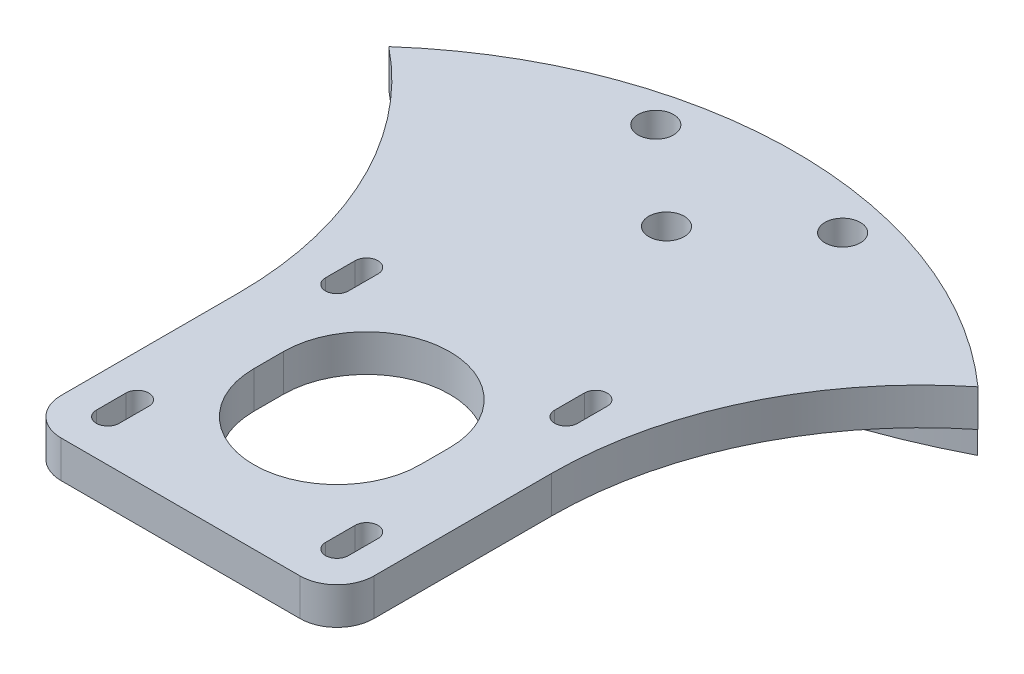
from build123d import *

# Parameters (mm, degrees)
SKETCH1_R                = 72.63
BOSS_EXTRUDE1_DEPTH      = 13
BOSS_EXTRUDE2_DEPTH      = 5
SKETCH4_R                = 85.63
BOSS_EXTRUDE3_DEPTH      = 3.5
BOSS_EXTRUDE3_DEPTH_BACK = 5
CUT_EXTRUDE1_DEPTH       = 6
FILLET1_R                = 50
FILLET2_R                = 5
SKETCH8_R                = 2.4
CUT_EXTRUDE2_DEPTH       = 9.5
SKETCH10_OUTSIDE_W       = 230.742
SKETCH10_OUTSIDE_H       = 289.594
SKETCH10_OUTSIDE_R       = 60
CUT_EXTRUDE3_DEPTH       = 19
SKETCH11_R               = 2.4
CUT_EXTRUDE4_DEPTH       = 19


with BuildPart() as part:
    # Sketch1 → Boss-Extrude1 (new body)
    with BuildSketch(Plane(origin=(0, 0, 0), x_dir=(1, 0, 0), z_dir=(0, 1, 0))):
        Circle(SKETCH1_R)
    extrude(amount=BOSS_EXTRUDE1_DEPTH)

    # Sketch2 → Boss-Extrude2 (add)
    with BuildSketch(Plane(origin=(0, 13, 0), x_dir=(1, 0, 0), z_dir=(0, 1, 0))):
        with BuildLine():
            Line((-21.15, -69.482331567), (-21.15, -144.482331567))
            Line((-21.15, -144.482331567), (21.15, -144.482331567))
            Line((21.15, -144.482331567), (21.15, -69.482331567))
            ThreePointArc((21.15, -69.482331567), (0, 72.63), (-21.15, -69.482331567))
        make_face()
    extrude(amount=BOSS_EXTRUDE2_DEPTH)

    # Sketch4 → Boss-Extrude3 (add, two sides)
    with BuildSketch(Plane.XZ.offset(-13)) as boss_extrude3_sk:
        Circle(SKETCH4_R)
    extrude(amount=BOSS_EXTRUDE3_DEPTH)
    extrude(boss_extrude3_sk.sketch, amount=-BOSS_EXTRUDE3_DEPTH_BACK)

    # Sketch5 → Cut-Extrude1 (cut, through all)
    with BuildSketch(Plane.XZ.offset(-13)):
        with BuildLine():
            Line((11.25, 123.332331567), (11.25, 119.332331567))
            ThreePointArc((11.25, 119.332331567), (0, 108.082331567), (-11.25, 119.332331567))
            Line((-11.25, 119.332331567), (-11.25, 123.332331567))
            ThreePointArc((-11.25, 123.332331567), (0, 134.582331567), (11.25, 123.332331567))
        make_face()
        with BuildLine():
            Line((17.05, 107.832331567), (17.05, 103.832331567))
            ThreePointArc((17.05, 103.832331567), (15.5, 102.282331567), (13.95, 103.832331567))
            Line((13.95, 103.832331567), (13.95, 107.832331567))
            ThreePointArc((13.95, 107.832331567), (15.5, 109.382331567), (17.05, 107.832331567))
        make_face()
        with BuildLine():
            Line((17.05, 138.832331567), (17.05, 134.832331567))
            ThreePointArc((17.05, 134.832331567), (15.5, 133.282331567), (13.95, 134.832331567))
            Line((13.95, 134.832331567), (13.95, 138.832331567))
            ThreePointArc((13.95, 138.832331567), (15.5, 140.382331567), (17.05, 138.832331567))
        make_face()
        with BuildLine():
            Line((-13.95, 138.832331567), (-13.95, 134.832331567))
            ThreePointArc((-13.95, 134.832331567), (-15.5, 133.282331567), (-17.05, 134.832331567))
            Line((-17.05, 134.832331567), (-17.05, 138.832331567))
            ThreePointArc((-17.05, 138.832331567), (-15.5, 140.382331567), (-13.95, 138.832331567))
        make_face()
        with BuildLine():
            Line((-13.95, 107.832331567), (-13.95, 103.832331567))
            ThreePointArc((-13.95, 103.832331567), (-15.5, 102.282331567), (-17.05, 103.832331567))
            Line((-17.05, 103.832331567), (-17.05, 107.832331567))
            ThreePointArc((-17.05, 107.832331567), (-15.5, 109.382331567), (-13.95, 107.832331567))
        make_face()
    extrude(amount=-CUT_EXTRUDE1_DEPTH, mode=Mode.SUBTRACT)

    # Fillet1
    fillet1_edges = [part.edges().sort_by_distance(p)[0] for p in [
        (-21.15, 15.5, 82.976951017),
        (21.15, 15.5, 82.976951017),
    ]]
    fillet(fillet1_edges, radius=FILLET1_R)

    # Fillet2
    fillet2_edges = [part.edges().sort_by_distance(p)[0] for p in [
        (-21.15, 15.5, 144.482331567),
        (21.15, 15.5, 144.482331567),
    ]]
    fillet(fillet2_edges, radius=FILLET2_R)

    # Sketch8 → Cut-Extrude2 (cut, through all)
    with BuildSketch(Plane.XZ.offset(-9.5)):
        with Locations((0, 78.7622)):
            Circle(SKETCH8_R)
    extrude(amount=-CUT_EXTRUDE2_DEPTH, mode=Mode.SUBTRACT)

    # Sketch10 outside → Cut-Extrude3 (cut, through all)
    with BuildSketch(Plane.XZ):
        with Locations((0, 29.426)):
            Rectangle(SKETCH10_OUTSIDE_W, SKETCH10_OUTSIDE_H)
        with Locations((0, 121.332331567)):
            Circle(SKETCH10_OUTSIDE_R, mode=Mode.SUBTRACT)
    extrude(amount=-CUT_EXTRUDE3_DEPTH, mode=Mode.SUBTRACT)

    # Sketch11 → Cut-Extrude4 (cut, through all)
    with BuildSketch(Plane.XZ):
        with Locations((-12.636876971, 67.569177035)):
            Circle(SKETCH11_R)
        with Locations((12.636876971, 67.569177035)):
            Circle(SKETCH11_R)
    extrude(amount=-CUT_EXTRUDE4_DEPTH, mode=Mode.SUBTRACT)


solid = part.part
